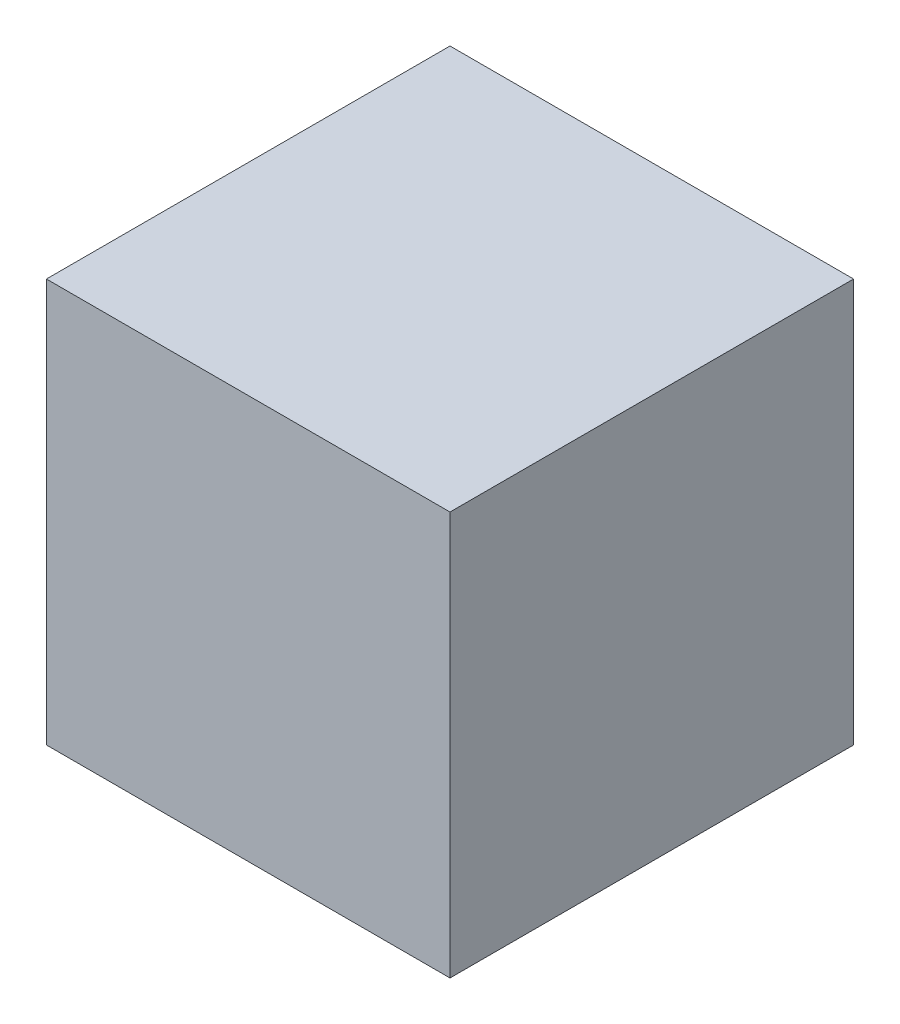
from build123d import *

# Parameters (mm, degrees)
SKETCH1_W           = 200
SKETCH1_H           = 200
BOSS_EXTRUDE1_DEPTH = 200


with BuildPart() as part:
    # Sketch1 → Boss-Extrude1 (new body)
    with BuildSketch(Plane.XY):
        Rectangle(SKETCH1_W, SKETCH1_H)
    extrude(amount=BOSS_EXTRUDE1_DEPTH)


solid = part.part
